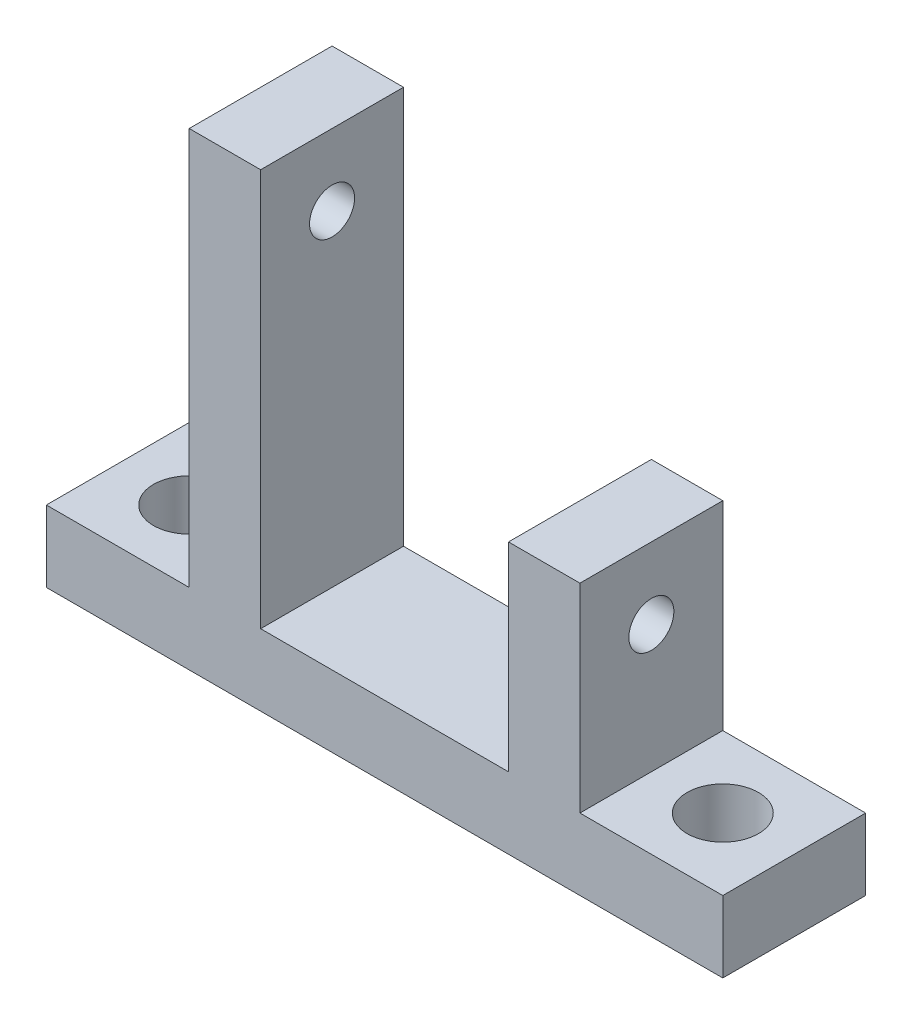
from build123d import *

# Parameters (mm, degrees)
SKETCH1_W           = 22.033357
SKETCH1_H           = 6.35
SKETCH1_W_2         = 12.7
BOSS_EXTRUDE1_DEPTH = 12.7
CUT_EXTRUDE1_REACH  = 49.433
SKETCH2_R           = 2
CUT_EXTRUDE2_REACH  = 8.35
SKETCH3_R           = 3.175
CUT_EXTRUDE3_REACH  = 49.433
SKETCH4_R           = 2


with BuildPart() as part:
    # Sketch1 → Boss-Extrude1 (new body)
    with BuildSketch(Plane.XY):
        Rectangle(SKETCH1_W, SKETCH1_H)
        Polygon((-11.0166785, -3.175), (-11.0166785, 3.175), (-11.0166785, 38.51148), (-17.3666785, 38.51148), (-17.3666785, 3.175), (-17.3666785, -3.175), align=None)
        Polygon((11.0166785, 20.87372), (11.0166785, 3.175), (11.0166785, -3.175), (17.3666785, -3.175), (17.3666785, 3.175), (17.3666785, 20.87372), align=None)
        with Locations((-23.7166785, 0)):
            Rectangle(SKETCH1_W_2, SKETCH1_H)
        with Locations((23.7166785, 0)):
            Rectangle(SKETCH1_W_2, SKETCH1_H)
    extrude(amount=BOSS_EXTRUDE1_DEPTH)

    # Sketch2 → Cut-Extrude1 (cut, up to next)
    with BuildSketch(Plane(origin=(17.3666785, 0, 0), x_dir=(0, 0, -1), z_dir=(1, 0, 0)), mode=Mode.PRIVATE) as cut_extrude1_sk1:
        with Locations((-6.35, 14.52372)):
            Circle(SKETCH2_R)
    cut_extrude1_tool1 = extrude(cut_extrude1_sk1.sketch, amount=-CUT_EXTRUDE1_REACH, mode=Mode.PRIVATE) & part.part
    add(cut_extrude1_tool1.solids().sort_by_distance((17.366678, 14.52372, 6.35))[0], mode=Mode.SUBTRACT)

    # Sketch3 → Cut-Extrude2 (cut, up to next)
    with BuildSketch(Plane(origin=(0, 3.175, 0), x_dir=(1, 0, 0), z_dir=(0, 1, 0)), mode=Mode.PRIVATE) as cut_extrude2_sk1:
        with Locations((-23.7166785, -6.35)):
            Circle(SKETCH3_R)
    cut_extrude2_tool1 = extrude(cut_extrude2_sk1.sketch, amount=-CUT_EXTRUDE2_REACH, mode=Mode.PRIVATE) & part.part
    add(cut_extrude2_tool1.solids().sort_by_distance((-23.716678, 3.175, 6.35))[0], mode=Mode.SUBTRACT)
    # Sketch3 → Cut-Extrude2 (cut, up to next)
    with BuildSketch(Plane(origin=(0, 3.175, 0), x_dir=(1, 0, 0), z_dir=(0, 1, 0)), mode=Mode.PRIVATE) as cut_extrude2_sk2:
        with Locations((23.7166785, -6.35)):
            Circle(SKETCH3_R)
    cut_extrude2_tool2 = extrude(cut_extrude2_sk2.sketch, amount=-CUT_EXTRUDE2_REACH, mode=Mode.PRIVATE) & part.part
    add(cut_extrude2_tool2.solids().sort_by_distance((23.716679, 3.175, 6.35))[0], mode=Mode.SUBTRACT)

    # Sketch4 → Cut-Extrude3 (cut, up to next)
    with BuildSketch(Plane.ZY.offset(17.3666785), mode=Mode.PRIVATE) as cut_extrude3_sk1:
        with Locations((6.35, 32.16148)):
            Circle(SKETCH4_R)
    cut_extrude3_tool1 = extrude(cut_extrude3_sk1.sketch, amount=-CUT_EXTRUDE3_REACH, mode=Mode.PRIVATE) & part.part
    add(cut_extrude3_tool1.solids().sort_by_distance((-17.366678, 32.16148, 6.35))[0], mode=Mode.SUBTRACT)


solid = part.part
